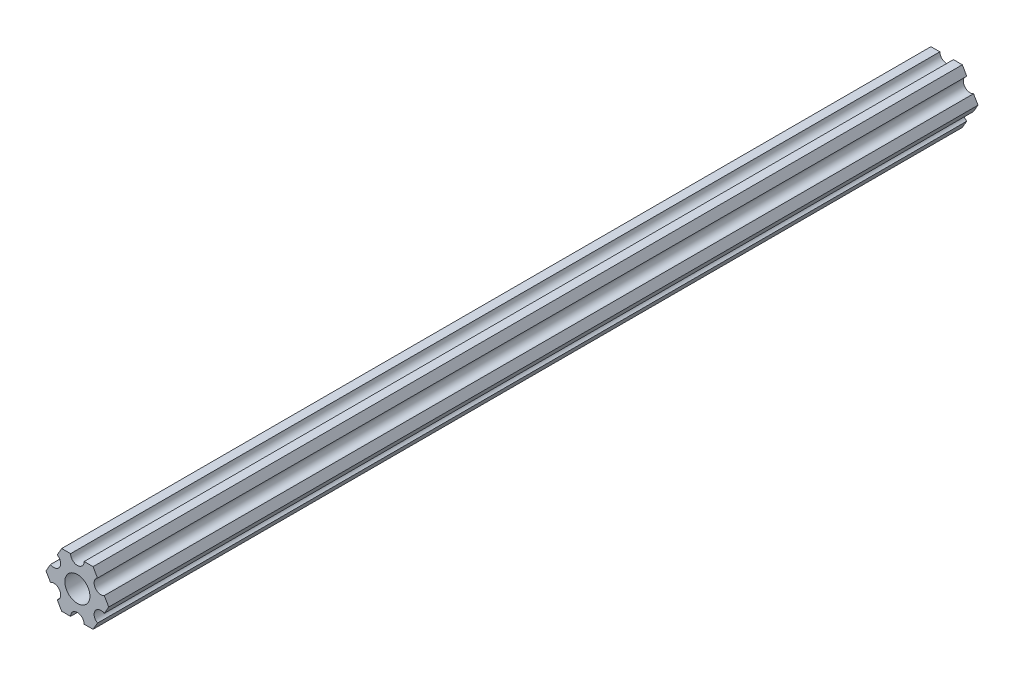
from build123d import *

# Parameters (mm, degrees)
SKETCH1_R           = 2.9337
BOSS_EXTRUDE1_DEPTH = 203.2


with BuildPart() as part:
    # Sketch1 → Boss-Extrude1 (new body)
    with BuildSketch(Plane.XY):
        with BuildLine():
            Line((-4.70551159, -4.549815043), (-3.666174521, -6.349999904))
            Line((-3.666174521, -6.349999904), (-1.587501154, -6.349999904))
            ThreePointArc((-1.587501154, -6.349999904), (-3.85e-07, -4.762499134), (1.587501154, -6.349999904))
            Line((1.587501154, -6.349999904), (3.666173825, -6.349999904))
            Line((3.666173825, -6.349999904), (4.705510929, -4.549815232))
            ThreePointArc((4.705510929, -4.549815232), (4.124445601, -2.381249904), (6.293010929, -1.800184575))
            Line((6.293010929, -1.800184575), (7.332348034, 9.6e-08))
            Line((7.332348034, 9.6e-08), (6.293011178, 1.800184715))
            ThreePointArc((6.293011178, 1.800184715), (4.124445902, 2.381250241), (4.705511428, 4.549815516))
            Line((4.705511428, 4.549815516), (3.666174521, 6.350000222))
            Line((3.666174521, 6.350000222), (1.587498846, 6.350000222))
            ThreePointArc((1.587498846, 6.350000222), (3.85e-07, 4.762501761), (-1.587498846, 6.350000222))
            Line((-1.587498846, 6.350000222), (-3.666173825, 6.350000222))
            Line((-3.666173825, 6.350000222), (-4.705511038, 4.549815614))
            ThreePointArc((-4.705511038, 4.549815614), (-4.124445841, 2.38125025), (-6.293011205, 1.800185053))
            Line((-6.293011205, 1.800185053), (-7.332348419, 4.44e-07))
            Line((-7.332348419, 4.44e-07), (-6.293011423, -1.80018429))
            ThreePointArc((-6.293011423, -1.80018429), (-4.12444613, -2.38124975), (-4.70551159, -4.549815043))
        make_face()
        Circle(SKETCH1_R, mode=Mode.SUBTRACT)
    extrude(amount=-BOSS_EXTRUDE1_DEPTH)


solid = part.part
